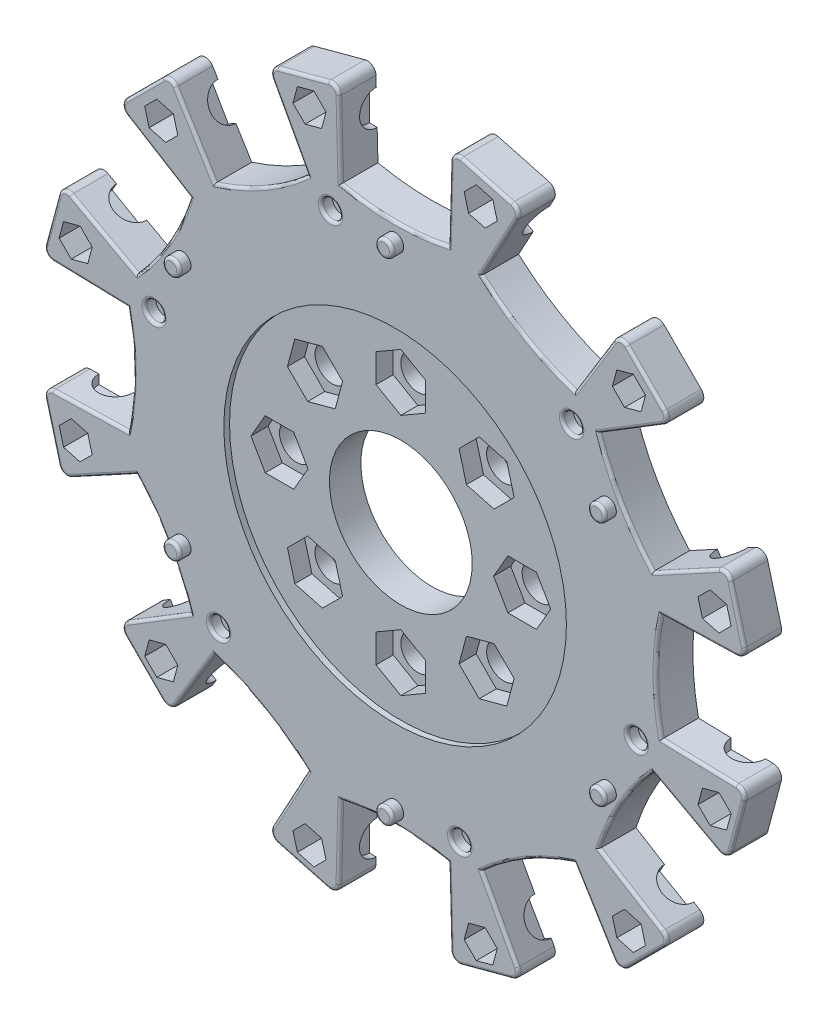
from build123d import *

# Parameters (mm, degrees)
BOSS_EXTRUDE1_DEPTH = 6.5
SKETCH5_W           = 22
SKETCH5_H           = 3
FILLET1_R           = 1.5
SKETCH6_R           = 12.5
SKETCH6_R_2         = 3
CUT_EXTRUDE1_DEPTH  = 88.203512833
SKETCH6_3_R         = 30
SKETCH6_3_R_2       = 12.5
CUT_EXTRUDE2_DEPTH  = 1
SKETCH6_4_R         = 3
CUT_EXTRUDE3_DEPTH  = 4
CIRPATTERN1_COUNT   = 12
SKETCH7_R           = 1.5
BOSS_EXTRUDE2_DEPTH = 2
FILLET2_R           = 0.5
SKETCH8_R           = 1.65
CUT_EXTRUDE4_DEPTH  = 2
FILLET3_R           = 0.5
FILLET5_R           = 0.5


with BuildPart() as part:
    # Sketch1 → Boss-Extrude1 (new body)
    with BuildSketch(Plane.XY):
        with BuildLine():
            Line((-22.45470819, 58.68804035), (-9.897672448, 62.052687936))
            Line((-9.897672448, 62.052687936), (-9.503290634, 47.0578734))
            ThreePointArc((-9.503290634, 47.0578734), (-0.088468514, 46.061976895), (9.326353606, 47.0578734))
            Line((9.326353606, 47.0578734), (9.72073542, 62.052687936))
            Line((9.72073542, 62.052687936), (22.277771162, 58.68804035))
            Line((22.277771162, 58.68804035), (15.121908564, 45.504959129))
            ThreePointArc((15.121908564, 45.504959129), (22.77743544, 39.935076397), (31.42885882, 36.090137009))
            Line((31.42885882, 36.090137009), (39.267810758, 48.878836416))
            Line((39.267810758, 48.878836416), (48.460198913, 39.68644826))
            Line((48.460198913, 39.68644826), (35.671499507, 31.847496322))
            ThreePointArc((35.671499507, 31.847496322), (39.516438894, 23.196072942), (45.086321627, 15.540546066))
            Line((45.086321627, 15.540546066), (58.269402848, 22.696408664))
            Line((58.269402848, 22.696408664), (61.634050434, 10.139372923))
            Line((61.634050434, 10.139372923), (46.639235897, 9.744991108))
            ThreePointArc((46.639235897, 9.744991108), (45.643339393, 0.330168988), (46.639235897, -9.084653131))
            Line((46.639235897, -9.084653131), (61.634050434, -9.479034946))
            Line((61.634050434, -9.479034946), (58.269402848, -22.036070687))
            Line((58.269402848, -22.036070687), (45.086321627, -14.880208089))
            ThreePointArc((45.086321627, -14.880208089), (39.516438895, -22.535734965), (35.671499507, -31.187158345))
            Line((35.671499507, -31.187158345), (48.460198913, -39.026110283))
            Line((48.460198913, -39.026110283), (39.267810758, -48.218498439))
            Line((39.267810758, -48.218498439), (31.42885882, -35.429799032))
            ThreePointArc((31.42885882, -35.429799032), (22.77743544, -39.27473842), (15.121908564, -44.844621152))
            Line((15.121908564, -44.844621152), (22.277771162, -58.027702373))
            Line((22.277771162, -58.027702373), (9.72073542, -61.392349959))
            Line((9.72073542, -61.392349959), (9.326353606, -46.397535423))
            ThreePointArc((9.326353606, -46.397535423), (-0.088468514, -45.401638918), (-9.503290634, -46.397535423))
            Line((-9.503290634, -46.397535423), (-9.897672448, -61.392349959))
            Line((-9.897672448, -61.392349959), (-22.45470819, -58.027702373))
            Line((-22.45470819, -58.027702373), (-15.298845591, -44.844621152))
            ThreePointArc((-15.298845591, -44.844621152), (-22.954372467, -39.27473842), (-31.605795847, -35.429799032))
            Line((-31.605795847, -35.429799032), (-39.444747786, -48.218498439))
            Line((-39.444747786, -48.218498439), (-48.637135941, -39.026110283))
            Line((-48.637135941, -39.026110283), (-35.848436535, -31.187158345))
            ThreePointArc((-35.848436535, -31.187158345), (-39.693375922, -22.535734965), (-45.263258654, -14.880208089))
            Line((-45.263258654, -14.880208089), (-58.446339875, -22.036070688))
            Line((-58.446339875, -22.036070688), (-61.810987462, -9.479034946))
            Line((-61.810987462, -9.479034946), (-46.816172925, -9.084653131))
            ThreePointArc((-46.816172925, -9.084653131), (-45.820276421, 0.330168988), (-46.816172925, 9.744991108))
            Line((-46.816172925, 9.744991108), (-61.810987462, 10.139372923))
            Line((-61.810987462, 10.139372923), (-58.446339875, 22.696408664))
            Line((-58.446339875, 22.696408664), (-45.263258654, 15.540546066))
            ThreePointArc((-45.263258654, 15.540546066), (-39.693375922, 23.196072942), (-35.848436535, 31.847496322))
            Line((-35.848436535, 31.847496322), (-48.637135941, 39.68644826))
            Line((-48.637135941, 39.68644826), (-39.444747786, 48.878836416))
            Line((-39.444747786, 48.878836416), (-31.605795847, 36.090137009))
            ThreePointArc((-31.605795847, 36.090137009), (-22.954372467, 39.935076397), (-15.298845591, 45.504959129))
            Line((-15.298845591, 45.504959129), (-22.45470819, 58.68804035))
        make_face()
        Polygon((12.86793822, 53.819354184), (15.765715699, 53.042897048), (17.887036043, 55.164217392), (17.110578907, 58.061994871), (14.212801428, 58.838452006), (12.091481085, 56.717131663), align=None, mode=Mode.SUBTRACT)
        Polygon((-12.091481085, 56.717131663), (-14.212801428, 58.838452006), (-17.110578907, 58.061994871), (-17.887036043, 55.164217392), (-15.765715699, 53.042897048), (-12.86793822, 53.819354184), align=None, mode=Mode.SUBTRACT)
        Polygon((38.053638485, 40.174958828), (40.174958828, 38.053638485), (43.072736307, 38.83009562), (43.849193443, 41.727873099), (41.727873099, 43.849193443), (38.83009562, 43.072736307), align=None, mode=Mode.SUBTRACT)
        Polygon((53.042897048, 15.765715699), (53.819354184, 12.86793822), (56.717131663, 12.091481085), (58.838452006, 14.212801428), (58.061994871, 17.110578907), (55.164217392, 17.887036043), align=None, mode=Mode.SUBTRACT)
        Polygon((53.819354184, -12.86793822), (53.042897048, -15.765715699), (55.164217392, -17.887036043), (58.061994871, -17.110578907), (58.838452006, -14.212801428), (56.717131663, -12.091481085), align=None, mode=Mode.SUBTRACT)
        Polygon((40.174958828, -38.053638485), (38.053638485, -40.174958828), (38.83009562, -43.072736307), (41.727873099, -43.849193443), (43.849193443, -41.727873099), (43.072736307, -38.83009562), align=None, mode=Mode.SUBTRACT)
        Polygon((15.765715699, -53.042897048), (12.86793822, -53.819354184), (12.091481085, -56.717131663), (14.212801428, -58.838452006), (17.110578907, -58.061994871), (17.887036043, -55.164217392), align=None, mode=Mode.SUBTRACT)
        Polygon((-12.86793822, -53.819354184), (-15.765715699, -53.042897048), (-17.887036042, -55.164217392), (-17.110578907, -58.061994871), (-14.212801428, -58.838452006), (-12.091481085, -56.717131663), align=None, mode=Mode.SUBTRACT)
        Polygon((-38.053638485, -40.174958828), (-40.174958828, -38.053638485), (-43.072736307, -38.83009562), (-43.849193443, -41.727873099), (-41.727873099, -43.849193443), (-38.83009562, -43.072736307), align=None, mode=Mode.SUBTRACT)
        Polygon((-53.042897048, -15.765715699), (-53.819354184, -12.86793822), (-56.717131663, -12.091481085), (-58.838452006, -14.212801428), (-58.061994871, -17.110578907), (-55.164217392, -17.887036043), align=None, mode=Mode.SUBTRACT)
        Polygon((-53.819354184, 12.86793822), (-53.042897048, 15.765715699), (-55.164217392, 17.887036043), (-58.061994871, 17.110578907), (-58.838452006, 14.212801428), (-56.717131663, 12.091481085), align=None, mode=Mode.SUBTRACT)
        Polygon((-40.174958828, 38.053638485), (-38.053638485, 40.174958828), (-38.83009562, 43.072736307), (-41.727873099, 43.849193443), (-43.849193443, 41.727873099), (-43.072736307, 38.83009562), align=None, mode=Mode.SUBTRACT)
    extrude(amount=BOSS_EXTRUDE1_DEPTH)

    # Sketch5 → Cut-Revolve2 (revolve, cut)
    with BuildSketch(Plane(origin=(0, 0, 0), x_dir=(-1, 0, 0), z_dir=(0, 0, -1))):
        with Locations((0, 56.86118568)):
            Rectangle(SKETCH5_W, SKETCH5_H)
    cut_revolve2 = revolve(axis=Axis((11, 55.36118568, 0), (-1, 0, 0)), mode=Mode.SUBTRACT)

    # Fillet1
    fillet1_edges = [part.edges().sort_by_distance(p)[0] for p in [
        (9.72073542, 62.052687936, 3.25),
        (22.277771162, 58.68804035, 3.25),
        (39.267810758, 48.878836416, 3.25),
        (48.460198913, 39.68644826, 3.25),
        (58.269402848, 22.696408664, 3.25),
        (61.634050434, 10.139372923, 3.25),
        (61.634050434, -9.479034946, 3.25),
        (58.269402848, -22.036070687, 3.25),
        (48.460198913, -39.026110283, 3.25),
        (39.267810758, -48.218498439, 3.25),
        (22.277771162, -58.027702373, 3.25),
        (9.72073542, -61.392349959, 3.25),
        (-9.897672448, -61.392349959, 3.25),
        (-22.45470819, -58.027702373, 3.25),
        (-39.444747786, -48.218498439, 3.25),
        (-48.637135941, -39.026110283, 3.25),
        (-58.446339875, -22.036070688, 3.25),
        (-61.810987462, -9.479034946, 3.25),
        (-61.810987462, 10.139372923, 3.25),
        (-58.446339875, 22.696408664, 3.25),
        (-48.637135941, 39.68644826, 3.25),
        (-39.444747786, 48.878836416, 3.25),
        (-22.45470819, 58.68804035, 3.25),
        (-9.897672448, 62.052687936, 3.25),
    ]]
    fillet(fillet1_edges, radius=FILLET1_R)

    # Sketch6 → Cut-Extrude1 (cut, through all)
    with BuildSketch(Plane.XY.offset(6.5)):
        Circle(SKETCH6_R)
        with Locations((0, 21.25)):
            Circle(SKETCH6_R_2)
        with Locations((15.0260191, 15.0260191)):
            Circle(SKETCH6_R_2)
        with Locations((21.25, 0)):
            Circle(SKETCH6_R_2)
        with Locations((15.0260191, -15.0260191)):
            Circle(SKETCH6_R_2)
        with Locations((0, -21.25)):
            Circle(SKETCH6_R_2)
        with Locations((-15.0260191, -15.0260191)):
            Circle(SKETCH6_R_2)
        with Locations((-21.25, 0)):
            Circle(SKETCH6_R_2)
        with Locations((-15.0260191, 15.0260191)):
            Circle(SKETCH6_R_2)
    extrude(amount=-CUT_EXTRUDE1_DEPTH, mode=Mode.SUBTRACT)

    # Sketch6_3 → Cut-Extrude2 (cut)
    with BuildSketch(Plane.XY.offset(6.5)):
        Circle(SKETCH6_3_R)
        Polygon((-18.561553006, -18.561553006), (-19.855648232, -13.731923875), (-16.320114326, -10.196389969), (-11.490485194, -11.490485194), (-10.196389969, -16.320114326), (-13.731923875, -19.855648232), align=None, mode=Mode.SUBTRACT)
        Polygon((-26.25, 0), (-23.75, 4.330127019), (-18.75, 4.330127019), (-16.25, 0), (-18.75, -4.330127019), (-23.75, -4.330127019), align=None, mode=Mode.SUBTRACT)
        Circle(SKETCH6_3_R_2, mode=Mode.SUBTRACT)
        Polygon((0, -26.25), (-4.330127019, -23.75), (-4.330127019, -18.75), (0, -16.25), (4.330127019, -18.75), (4.330127019, -23.75), align=None, mode=Mode.SUBTRACT)
        Polygon((18.561553006, -18.561553006), (13.731923875, -19.855648232), (10.196389969, -16.320114326), (11.490485194, -11.490485194), (16.320114326, -10.196389969), (19.855648232, -13.731923875), align=None, mode=Mode.SUBTRACT)
        Polygon((-18.561553006, 18.561553006), (-13.731923875, 19.855648232), (-10.196389969, 16.320114326), (-11.490485194, 11.490485194), (-16.320114326, 10.196389969), (-19.855648232, 13.731923875), align=None, mode=Mode.SUBTRACT)
        Polygon((26.25, 0), (23.75, -4.330127019), (18.75, -4.330127019), (16.25, 0), (18.75, 4.330127019), (23.75, 4.330127019), align=None, mode=Mode.SUBTRACT)
        Polygon((0, 26.25), (4.330127019, 23.75), (4.330127019, 18.75), (0, 16.25), (-4.330127019, 18.75), (-4.330127019, 23.75), align=None, mode=Mode.SUBTRACT)
        Polygon((18.561553006, 18.561553006), (19.855648232, 13.731923875), (16.320114326, 10.196389969), (11.490485194, 11.490485194), (10.196389969, 16.320114326), (13.731923875, 19.855648232), align=None, mode=Mode.SUBTRACT)
    extrude(amount=-CUT_EXTRUDE2_DEPTH, mode=Mode.SUBTRACT)

    # Sketch6_4 → Cut-Extrude3 (cut)
    # profile 1 of 8: a face of its own
    with BuildSketch(Plane.XY.offset(6.5)):
        Polygon((16.320114326, 10.196389969), (19.855648232, 13.731923875), (18.561553006, 18.561553006), (13.731923875, 19.855648232), (10.196389969, 16.320114326), (11.490485194, 11.490485194), align=None)
        with Locations((15.0260191, 15.0260191)):
            Circle(SKETCH6_4_R, mode=Mode.SUBTRACT)
    # profile 2 of 8: a face of its own
    with BuildSketch(Plane.XY.offset(6.5)):
        Polygon((4.330127019, 18.75), (4.330127019, 23.75), (0, 26.25), (-4.330127019, 23.75), (-4.330127019, 18.75), (0, 16.25), align=None)
        with Locations((0, 21.25)):
            Circle(SKETCH6_4_R, mode=Mode.SUBTRACT)
    # profile 3 of 8: a face of its own
    with BuildSketch(Plane.XY.offset(6.5)):
        Polygon((18.75, -4.330127019), (23.75, -4.330127019), (26.25, 0), (23.75, 4.330127019), (18.75, 4.330127019), (16.25, 0), align=None)
        with Locations((21.25, 0)):
            Circle(SKETCH6_4_R, mode=Mode.SUBTRACT)
    # profile 4 of 8: a face of its own
    with BuildSketch(Plane.XY.offset(6.5)):
        Polygon((10.196389969, -16.320114326), (13.731923875, -19.855648232), (18.561553006, -18.561553006), (19.855648232, -13.731923875), (16.320114326, -10.196389969), (11.490485194, -11.490485194), align=None)
        with Locations((15.0260191, -15.0260191)):
            Circle(SKETCH6_4_R, mode=Mode.SUBTRACT)
    # profile 5 of 8: a face of its own
    with BuildSketch(Plane.XY.offset(6.5)):
        Polygon((-4.330127019, -18.75), (-4.330127019, -23.75), (0, -26.25), (4.330127019, -23.75), (4.330127019, -18.75), (0, -16.25), align=None)
        with Locations((0, -21.25)):
            Circle(SKETCH6_4_R, mode=Mode.SUBTRACT)
    # profile 6 of 8: a face of its own
    with BuildSketch(Plane.XY.offset(6.5)):
        Polygon((-16.320114326, -10.196389969), (-19.855648232, -13.731923875), (-18.561553006, -18.561553006), (-13.731923875, -19.855648232), (-10.196389969, -16.320114326), (-11.490485194, -11.490485194), align=None)
        with Locations((-15.0260191, -15.0260191)):
            Circle(SKETCH6_4_R, mode=Mode.SUBTRACT)
    # profile 7 of 8: a face of its own
    with BuildSketch(Plane.XY.offset(6.5)):
        Polygon((-18.75, 4.330127019), (-23.75, 4.330127019), (-26.25, 0), (-23.75, -4.330127019), (-18.75, -4.330127019), (-16.25, 0), align=None)
        with Locations((-21.25, 0)):
            Circle(SKETCH6_4_R, mode=Mode.SUBTRACT)
    # profile 8 of 8: a face of its own
    with BuildSketch(Plane.XY.offset(6.5)):
        Polygon((-10.196389969, 16.320114326), (-13.731923875, 19.855648232), (-18.561553006, 18.561553006), (-19.855648232, 13.731923875), (-16.320114326, 10.196389969), (-11.490485194, 11.490485194), align=None)
        with Locations((-15.0260191, 15.0260191)):
            Circle(SKETCH6_4_R, mode=Mode.SUBTRACT)
    extrude(amount=-CUT_EXTRUDE3_DEPTH, mode=Mode.SUBTRACT)

    # CirPattern1: Cut-Revolve2 ×12 about axis
    cirpattern1_axis = Axis((0, 0, 0), (0, 0, 1))
    for i in range(1, CIRPATTERN1_COUNT):
        add(cut_revolve2.rotate(cirpattern1_axis, i * 360 / CIRPATTERN1_COUNT), mode=Mode.SUBTRACT)

    # Sketch7 → Boss-Extrude2 (add)
    with BuildSketch(Plane.XY.offset(6.5)):
        with Locations((0, 43)):
            Circle(SKETCH7_R)
        with Locations((37.239092363, 21.5)):
            Circle(SKETCH7_R)
        with Locations((37.239092363, -21.5)):
            Circle(SKETCH7_R)
        with Locations((0, -43)):
            Circle(SKETCH7_R)
        with Locations((-37.239092363, -21.5)):
            Circle(SKETCH7_R)
        with Locations((-37.239092363, 21.5)):
            Circle(SKETCH7_R)
    extrude(amount=BOSS_EXTRUDE2_DEPTH)

    # Fillet2
    fillet2_edges = [part.edges().sort_by_distance(p)[0] for p in [
        (-38.739092363, 21.5, 8.5),
        (-38.739092363, -21.5, 8.5),
        (-1.5, -43, 8.5),
        (35.739092363, -21.5, 8.5),
        (35.739092363, 21.5, 8.5),
        (-1.5, 43, 8.5),
    ]]
    fillet(fillet2_edges, radius=FILLET2_R)

    # Sketch8 → Cut-Extrude4 (cut)
    with BuildSketch(Plane.XY.offset(6.5)):
        with Locations((-11.313824103, 42.223766382)):
            Circle(SKETCH8_R)
        with Locations((30.909942278, 30.909942278)):
            Circle(SKETCH8_R)
        with Locations((42.223766382, -11.313824103)):
            Circle(SKETCH8_R)
        with Locations((11.313824103, -42.223766382)):
            Circle(SKETCH8_R)
        with Locations((-30.909942278, -30.909942278)):
            Circle(SKETCH8_R)
        with Locations((-42.223766382, 11.313824103)):
            Circle(SKETCH8_R)
    extrude(amount=-CUT_EXTRUDE4_DEPTH, mode=Mode.SUBTRACT)

    # Fillet3
    fillet3_edges = [part.edges().sort_by_distance(p)[0] for p in [
        (-43.873766382, 11.313824103, 6.5),
        (-32.559942278, -30.909942278, 6.5),
        (9.663824103, -42.223766382, 6.5),
        (40.573766382, -11.313824103, 6.5),
        (29.259942278, 30.909942278, 6.5),
        (-12.963824103, 42.223766382, 6.5),
    ]]
    fillet(fillet3_edges, radius=FILLET3_R)

    # Fillet5
    fillet5_edges = [part.edges().sort_by_distance(p)[0] for p in [
        (21.430006444, 58.32375403, 6.5),
        (18.246035213, 51.260465862, 6.5),
        (22.77743544, 39.935076397, 6.5),
        (34.851210537, 41.673463419, 6.5),
        (39.37621191, 47.962507474, 6.5),
        (43.864004836, 44.282642338, 6.5),
        (47.543869971, 39.794849412, 6.5),
        (41.254825916, 35.26984804, 6.5),
        (39.516438894, 23.196072942, 6.5),
        (50.84182836, 18.664672716, 6.5),
        (57.905116528, 21.848643946, 6.5),
        (59.951726641, 16.417890794, 6.5),
        (60.894686868, 10.691415545, 6.5),
        (53.185714265, 9.917171432, 6.5),
        (45.643339393, 0.330168988, 6.5),
        (53.185714265, -9.256833455, 6.5),
        (60.894686868, -10.031077568, 6.5),
        (59.951726641, -15.757552817, 6.5),
        (57.905116528, -21.18830597, 6.5),
        (50.84182836, -18.004334739, 6.5),
        (39.516438895, -22.535734965, 6.5),
        (41.254825916, -34.609510063, 6.5),
        (47.543869971, -39.134511435, 6.5),
        (43.864004836, -43.622304361, 6.5),
        (39.37621191, -47.302169497, 6.5),
        (34.851210537, -41.013125442, 6.5),
        (22.77743544, -39.27473842, 6.5),
        (18.246035213, -50.600127885, 6.5),
        (21.430006444, -57.663416053, 6.5),
        (15.999253291, -59.710026166, 6.5),
        (10.272778043, -60.652986393, 6.5),
        (9.498533929, -52.94401379, 6.5),
        (-0.088468514, -45.401638918, 6.5),
        (-9.675470957, -52.94401379, 6.5),
        (-10.44971507, -60.652986393, 6.5),
        (-16.176190319, -59.710026166, 6.5),
        (-21.606943472, -57.663416053, 6.5),
        (-18.422972241, -50.600127885, 6.5),
        (-22.954372467, -39.27473842, 6.5),
        (-35.028147565, -41.013125442, 6.5),
        (-39.553148938, -47.302169497, 6.5),
        (-44.040941863, -43.622304361, 6.5),
        (-47.720806999, -39.134511435, 6.5),
        (-41.431762944, -34.609510063, 6.5),
        (-39.693375922, -22.535734965, 6.5),
        (-51.018765387, -18.004334739, 6.5),
        (-58.082053556, -21.18830597, 6.5),
        (-60.128663668, -15.757552817, 6.5),
        (-61.071623896, -10.031077568, 6.5),
        (-53.362651292, -9.256833455, 6.5),
        (-45.820276421, 0.330168988, 6.5),
        (-53.362651292, 9.917171432, 6.5),
        (-61.071623896, 10.691415545, 6.5),
        (-60.128663668, 16.417890794, 6.5),
        (-58.082053556, 21.848643946, 6.5),
        (-51.018765387, 18.664672716, 6.5),
        (-39.693375922, 23.196072942, 6.5),
        (-41.431762944, 35.26984804, 6.5),
        (-47.720806999, 39.794849412, 6.5),
        (-44.040941863, 44.282642338, 6.5),
        (-39.553148938, 47.962507474, 6.5),
        (-35.028147565, 41.673463419, 6.5),
        (-22.954372467, 39.935076397, 6.5),
        (-18.422972241, 51.260465862, 6.5),
        (-21.606943472, 58.32375403, 6.5),
        (-16.176190319, 60.370364143, 6.5),
        (-10.44971507, 61.31332437, 6.5),
        (-9.675470957, 53.604351767, 6.5),
        (-0.088468514, 46.061976895, 6.5),
        (10.272778043, 61.31332437, 6.5),
        (15.999253291, 60.370364143, 6.5),
        (9.498533929, 53.604351767, 6.5),
    ]]
    fillet(fillet5_edges, radius=FILLET5_R)


solid = part.part
